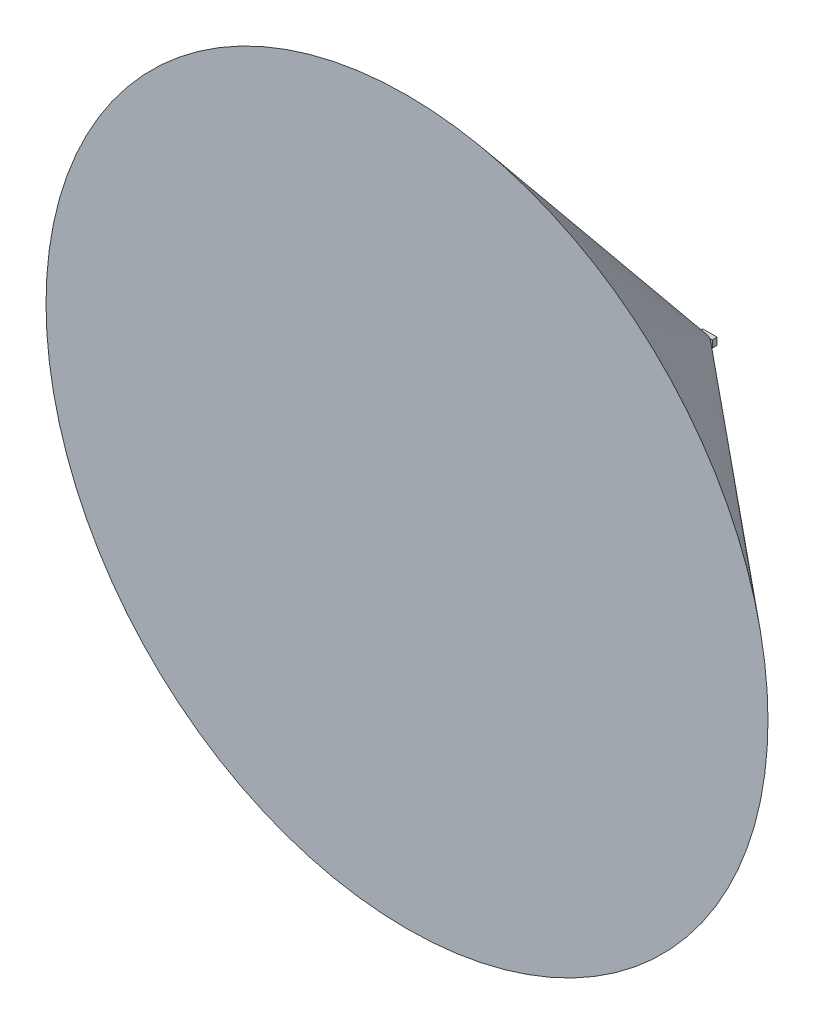
from build123d import *

# Parameters (mm, degrees)
SKETCH1_W           = 38.1
SKETCH1_H           = 19.05
BOSS_EXTRUDE1_DEPTH = 12.7


with BuildPart() as part:
    # Sketch1 → Boss-Extrude1 (new body)
    with BuildSketch(Plane.XY):
        Rectangle(SKETCH1_W, SKETCH1_H)
    extrude(amount=BOSS_EXTRUDE1_DEPTH)

    # Sketch2 → Revolve1 (revolve)
    with BuildSketch(Plane(origin=(0, 0, 0), x_dir=(0, 0, -1), z_dir=(1, 0, 0))):
        Polygon((0, 0), (-800, 953.402874075), (-800, 0), align=None)
    revolve(axis=Axis((0, 0, 800), (0, 0, -1)))


solid = part.part
